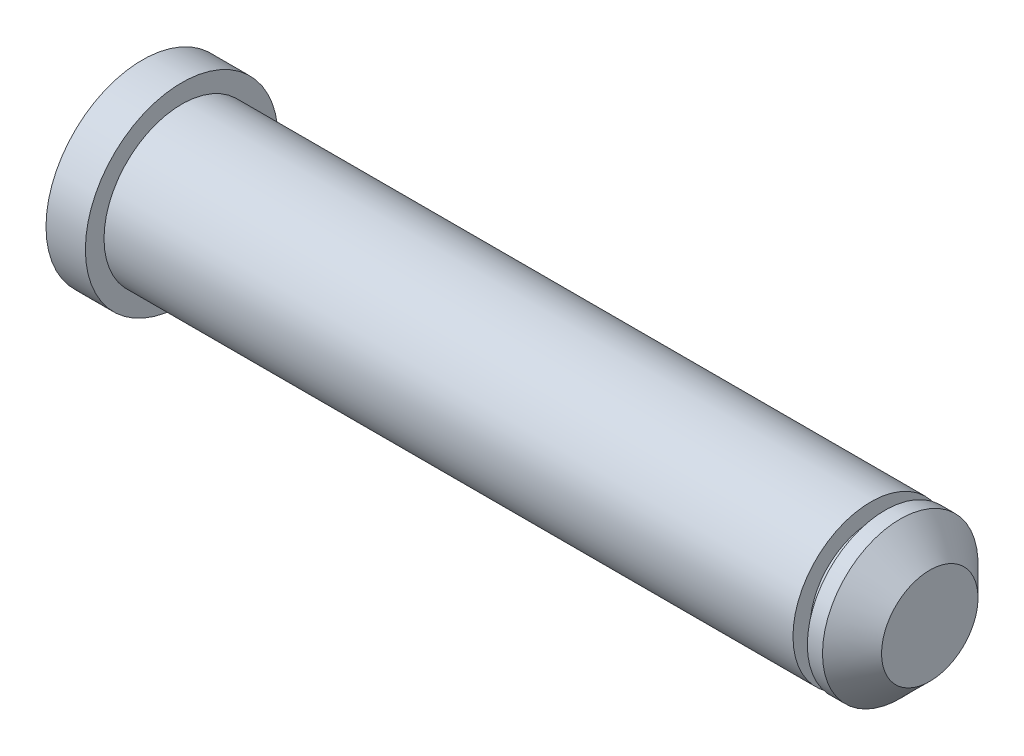
from build123d import *


with BuildPart() as part:
    # Sketch1 → Revolve1 (revolve)
    with BuildSketch(Plane.XY):
        Polygon((0, 0), (0, 4.896641555), (2, 4.896641555), (2, 3.95), (37, 3.95), (37, 3.08), (37.73, 3.08), (37.73, 3.95), (38.5, 3.95), (40, 2.45), (40, 0), align=None)
    revolve(axis=Axis((0, 0, 0), (1, 0, 0)))


solid = part.part
